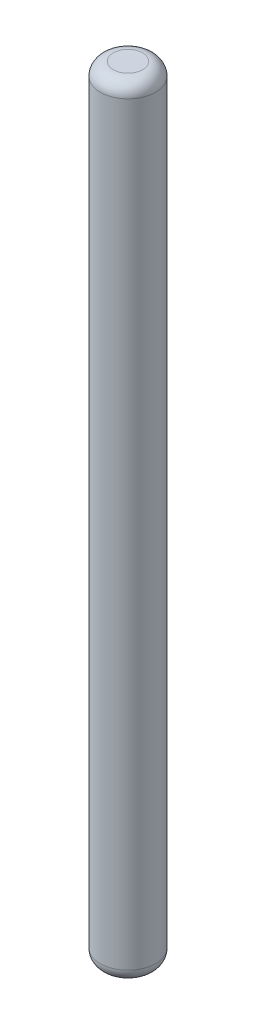
from build123d import *

# Parameters (mm, degrees)
SKETCH1_R           = 2.125
BOSS_EXTRUDE1_DEPTH = 60
FILLET1_R           = 1


with BuildPart() as part:
    # Sketch1 → Boss-Extrude1 (new body)
    with BuildSketch(Plane(origin=(0, 0, 0), x_dir=(1, 0, 0), z_dir=(0, 1, 0))):
        Circle(SKETCH1_R)
    extrude(amount=BOSS_EXTRUDE1_DEPTH)

    # Fillet1
    fillet1_edges = [part.edges().sort_by_distance(p)[0] for p in [
        (-2.125, 0, 0),
        (-2.125, 60, 0),
    ]]
    fillet(fillet1_edges, radius=FILLET1_R)


solid = part.part
